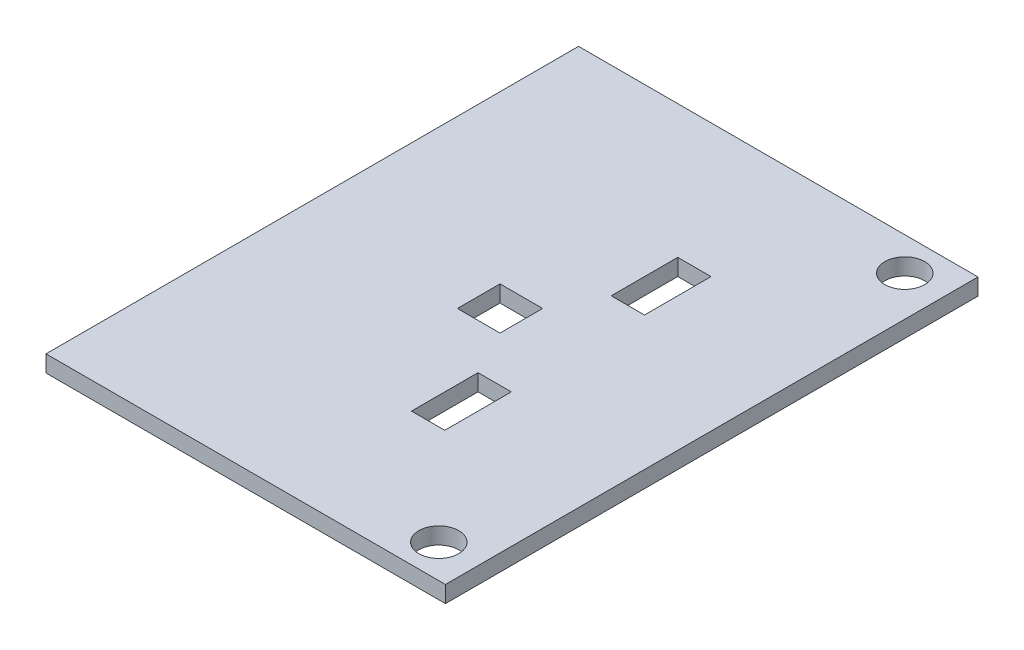
from build123d import *

# Parameters (mm, degrees)
SKETCH1_W           = 76.2
SKETCH1_H           = 101.6
BOSS_EXTRUDE1_DEPTH = 3.175
SKETCH2_R           = 3.81
SKETCH2_W           = 6.35
SKETCH2_H           = 12.7
SKETCH2_W_2         = 8.128
SKETCH2_H_2         = 8.128
CUT_EXTRUDE1_DEPTH  = 4.175


with BuildPart() as part:
    # Sketch1 → Boss-Extrude1 (new body)
    with BuildSketch(Plane(origin=(0, 0, 0), x_dir=(1, 0, 0), z_dir=(0, 1, 0))):
        with Locations((38.1, 50.8)):
            Rectangle(SKETCH1_W, SKETCH1_H)
    extrude(amount=BOSS_EXTRUDE1_DEPTH)

    # Sketch2 → Cut-Extrude1 (cut, through all)
    with BuildSketch(Plane(origin=(0, 3.175, 0), x_dir=(1, 0, 0), z_dir=(0, 1, 0))):
        with Locations((68.58, 95.25)):
            Circle(SKETCH2_R)
        with Locations((68.58, 6.35)):
            Circle(SKETCH2_R)
        with Locations((47.498, 69.85)):
            Rectangle(SKETCH2_W, SKETCH2_H)
        with Locations((47.498, 31.75)):
            Rectangle(SKETCH2_W, SKETCH2_H)
        with Locations((35.814, 50.8)):
            Rectangle(SKETCH2_W_2, SKETCH2_H_2)
    extrude(amount=-CUT_EXTRUDE1_DEPTH, mode=Mode.SUBTRACT)


solid = part.part
